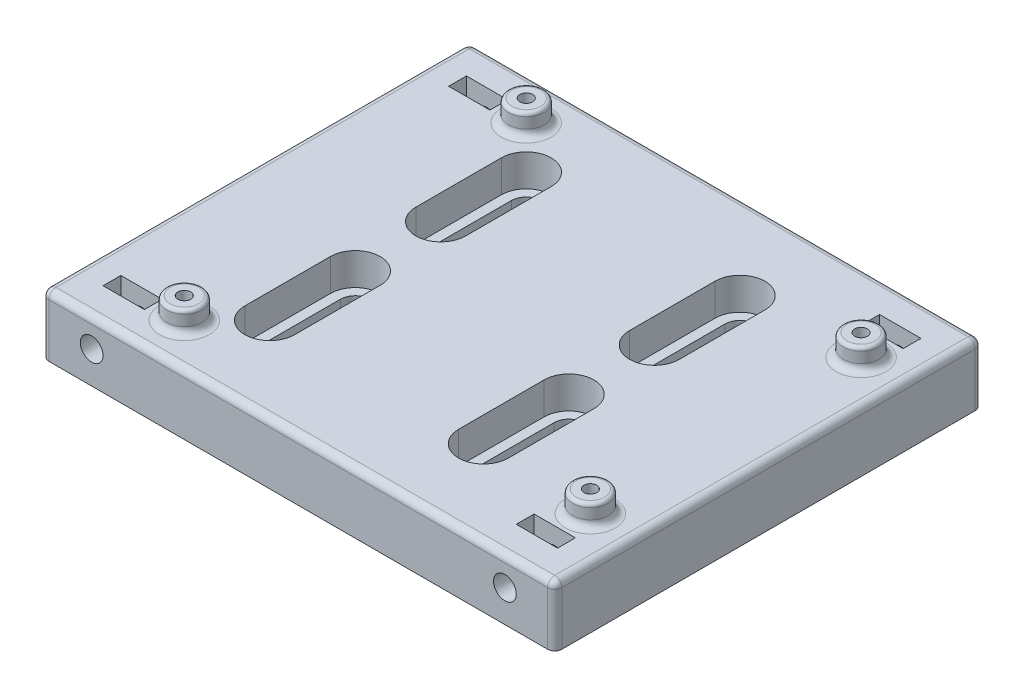
from build123d import *

# Parameters (mm, degrees)
SKETCH1_W           = 70
SKETCH1_H           = 56
BOSS_EXTRUDE1_DEPTH = 4
SKETCH2_W           = 70
SKETCH2_H           = 56
BOSS_EXTRUDE2_DEPTH = 4.5
SKETCH5_W           = 70
SKETCH5_H           = 8.5
BOSS_EXTRUDE3_DEPTH = 2
SKETCH6_W           = 70
SKETCH6_H           = 8.5
BOSS_EXTRUDE4_DEPTH = 2
SKETCH7_R           = 2.5
SKETCH7_R_2         = 0.9
BOSS_EXTRUDE5_DEPTH = 3
FILLET2_R           = 1
FILLET4_R           = 0.5
CUT_EXTRUDE6_START  = -30
SKETCH7_4_R         = 0.9
CUT_EXTRUDE6_DEPTH  = 30
SKETCH8_W           = 60
SKETCH8_H           = 8.5
BOSS_EXTRUDE6_DEPTH = 2
CUT_EXTRUDE2_DEPTH  = 7
SKETCH9_8_R         = 1.6
BOSS_EXTRUDE8_DEPTH = 4.5
SKETCH9_9_R         = 1.6
CUT_EXTRUDE4_DEPTH  = 10
SKETCH11_W          = 74.912856335
SKETCH11_H          = 22.458830191
CUT_EXTRUDE5_DEPTH  = 30
FILLET5_R           = 1


with BuildPart() as part:
    # Sketch1 → Boss-Extrude1 (new body)
    with BuildSketch(Plane(origin=(0, 0, 0), x_dir=(1, 0, 0), z_dir=(0, 1, 0))):
        with Locations((35, -28)):
            Rectangle(SKETCH1_W, SKETCH1_H)
        with BuildLine():
            ThreePointArc((52.1, -22), (50, -24.1), (47.9, -22))
            Line((47.9, -22), (47.9, -10))
            ThreePointArc((47.9, -10), (50, -7.9), (52.1, -10))
            Line((52.1, -10), (52.1, -22))
        make_face(mode=Mode.SUBTRACT)
        with BuildLine():
            ThreePointArc((52.1, -46), (50, -48.1), (47.9, -46))
            Line((47.9, -46), (47.9, -34))
            ThreePointArc((47.9, -34), (50, -31.9), (52.1, -34))
            Line((52.1, -34), (52.1, -46))
        make_face(mode=Mode.SUBTRACT)
        with BuildLine():
            ThreePointArc((17.9, -10), (20, -7.9), (22.1, -10))
            Line((22.1, -10), (22.1, -22))
            ThreePointArc((22.1, -22), (20, -24.1), (17.9, -22))
            Line((17.9, -22), (17.9, -10))
        make_face(mode=Mode.SUBTRACT)
        with BuildLine():
            Line((22.1, -34), (22.1, -46))
            ThreePointArc((22.1, -46), (20, -48.1), (17.9, -46))
            Line((17.9, -46), (17.9, -34))
            ThreePointArc((17.9, -34), (20, -31.9), (22.1, -34))
        make_face(mode=Mode.SUBTRACT)
    extrude(amount=BOSS_EXTRUDE1_DEPTH)

    # Sketch2 → Boss-Extrude2 (add)
    with BuildSketch(Plane(origin=(0, 4, 0), x_dir=(1, 0, 0), z_dir=(0, 1, 0))):
        with Locations((35, -28)):
            Rectangle(SKETCH2_W, SKETCH2_H)
        with BuildLine():
            Line((23.5, -22), (23.5, -10))
            ThreePointArc((23.5, -10), (20, -6.5), (16.5, -10))
            Line((16.5, -10), (16.5, -22))
            ThreePointArc((16.5, -22), (20, -25.5), (23.5, -22))
        make_face(mode=Mode.SUBTRACT)
        with BuildLine():
            Line((46.5, -10), (46.5, -22))
            ThreePointArc((46.5, -22), (50, -25.5), (53.5, -22))
            Line((53.5, -22), (53.5, -10))
            ThreePointArc((53.5, -10), (50, -6.5), (46.5, -10))
        make_face(mode=Mode.SUBTRACT)
        with BuildLine():
            Line((16.5, -34), (16.5, -46))
            ThreePointArc((16.5, -46), (20, -49.5), (23.5, -46))
            Line((23.5, -46), (23.5, -34))
            ThreePointArc((23.5, -34), (20, -30.5), (16.5, -34))
        make_face(mode=Mode.SUBTRACT)
        with BuildLine():
            Line((46.5, -34), (46.5, -46))
            ThreePointArc((46.5, -46), (50, -49.5), (53.5, -46))
            Line((53.5, -46), (53.5, -34))
            ThreePointArc((53.5, -34), (50, -30.5), (46.5, -34))
        make_face(mode=Mode.SUBTRACT)
    extrude(amount=BOSS_EXTRUDE2_DEPTH)

    # Sketch5 → Boss-Extrude3 (add)
    with BuildSketch(Plane.XY.offset(56)):
        with Locations((35, 4.25)):
            Rectangle(SKETCH5_W, SKETCH5_H)
    extrude(amount=BOSS_EXTRUDE3_DEPTH)

    # Sketch6 → Boss-Extrude4 (add)
    with BuildSketch(Plane(origin=(0, 0, 0), x_dir=(-1, 0, 0), z_dir=(0, 0, -1))):
        with Locations((-35, 4.25)):
            Rectangle(SKETCH6_W, SKETCH6_H)
    extrude(amount=BOSS_EXTRUDE4_DEPTH)

    # Sketch7 → Boss-Extrude5 (add)
    # profile 1 of 4: a face of its own
    with BuildSketch(Plane(origin=(0, 8.5, 0), x_dir=(1, 0, 0), z_dir=(0, 1, 0))):
        with Locations((14, -4)):
            Circle(SKETCH7_R)
        with Locations((14, -4)):
            Circle(SKETCH7_R_2, mode=Mode.SUBTRACT)
    # profile 2 of 4: a face of its own
    with BuildSketch(Plane(origin=(0, 8.5, 0), x_dir=(1, 0, 0), z_dir=(0, 1, 0))):
        with Locations((14, -52)):
            Circle(SKETCH7_R)
        with Locations((14, -52)):
            Circle(SKETCH7_R_2, mode=Mode.SUBTRACT)
    # profile 3 of 4: a face of its own
    with BuildSketch(Plane(origin=(0, 8.5, 0), x_dir=(1, 0, 0), z_dir=(0, 1, 0))):
        with Locations((66, -47)):
            Circle(SKETCH7_R)
        with Locations((66, -47)):
            Circle(SKETCH7_R_2, mode=Mode.SUBTRACT)
    # profile 4 of 4: a face of its own
    with BuildSketch(Plane(origin=(0, 8.5, 0), x_dir=(1, 0, 0), z_dir=(0, 1, 0))):
        with Locations((39.372259971, -13.674819386)):
            Circle(SKETCH7_R)
    extrude(amount=BOSS_EXTRUDE5_DEPTH)

    # Fillet2
    fillet2_edges = [part.edges().sort_by_distance(p)[0] for p in [
        (63.5, 8.5, 47),
        (36.872259971, 8.5, 13.674819386),
        (11.5, 8.5, 52),
        (11.5, 8.5, 4),
    ]]
    fillet(fillet2_edges, radius=FILLET2_R)

    # Fillet4
    fillet4_edges = [part.edges().sort_by_distance(p)[0] for p in [
        (63.5, 11.5, 47),
        (36.872259971, 11.5, 13.674819386),
        (11.5, 11.5, 52),
        (11.5, 11.5, 4),
    ]]
    fillet(fillet4_edges, radius=FILLET4_R)

    # Sketch7_4 → Cut-Extrude6 (cut)
    with BuildSketch(Plane(origin=(0, 8.5, 0), x_dir=(1, 0, 0), z_dir=(0, 1, 0)).offset(CUT_EXTRUDE6_START)):
        with Locations((14, -52)):
            Circle(SKETCH7_4_R)
        with Locations((66, -47)):
            Circle(SKETCH7_4_R)
    extrude(amount=CUT_EXTRUDE6_DEPTH, mode=Mode.SUBTRACT)

    # Sketch8 → Boss-Extrude6 (add)
    with BuildSketch(Plane(origin=(70, 0, 0), x_dir=(0, 0, -1), z_dir=(1, 0, 0))):
        with Locations((-28, 4.25)):
            Rectangle(SKETCH8_W, SKETCH8_H)
    extrude(amount=BOSS_EXTRUDE6_DEPTH)

    # Sketch9 → Cut-Extrude2 (cut)
    with BuildSketch(Plane.XY.offset(58)):
        Polygon((4.1, 2.825684219), (7, 1.151368439), (9.9, 2.825684219), (9.9, 8.5), (4.1, 8.5), align=None)
        Polygon((67.9, 8.5), (62.1, 8.5), (62.1, 2.825684219), (65, 1.151368439), (67.9, 2.825684219), align=None)
    extrude(amount=-CUT_EXTRUDE2_DEPTH, mode=Mode.SUBTRACT)

    # Sketch9_8 → Boss-Extrude8 (add)
    # profile 1 of 2: a face of its own
    with BuildSketch(Plane.XY.offset(58)):
        Polygon((4.1, 2.825684219), (7, 1.151368439), (9.9, 2.825684219), (9.9, 8.5), (4.1, 8.5), align=None)
        with Locations((7, 4.5)):
            Circle(SKETCH9_8_R, mode=Mode.SUBTRACT)
    # profile 2 of 2: a face of its own
    with BuildSketch(Plane.XY.offset(58)):
        Polygon((67.9, 8.5), (62.1, 8.5), (62.1, 2.825684219), (65, 1.151368439), (67.9, 2.825684219), align=None)
        with Locations((65, 4.5)):
            Circle(SKETCH9_8_R, mode=Mode.SUBTRACT)
    extrude(amount=-BOSS_EXTRUDE8_DEPTH)

    # Sketch9_9 → Cut-Extrude4 (cut)
    with BuildSketch(Plane.XY.offset(58)):
        with Locations((7, 4.5)):
            Circle(SKETCH9_9_R)
        with Locations((65, 4.5)):
            Circle(SKETCH9_9_R)
    extrude(amount=-CUT_EXTRUDE4_DEPTH, mode=Mode.SUBTRACT)

    # Sketch11 → Cut-Extrude5 (cut)
    with BuildSketch(Plane(origin=(0, 0, -2), x_dir=(-1, 0, 0), z_dir=(0, 0, -1))):
        with Locations((-34.543571832, 11.229415096)):
            Rectangle(SKETCH11_W, SKETCH11_H)
    extrude(amount=-CUT_EXTRUDE5_DEPTH, mode=Mode.SUBTRACT)

    # Mirror2: part across plane


with BuildPart() as part_1:
    add(part.part)
    add(part.part.mirror(Plane.XY.offset(28)))

    # Fillet5
    fillet5_edges = [part_1.edges().sort_by_distance(p)[0] for p in [
        (72, 8.5, 28),
        (36, 8.5, 58),
        (0, 8.5, 28),
        (36, 8.5, -2),
        (0, 4.25, -2),
        (72, 4.25, -2),
        (72, 4.25, 58),
        (0, 4.25, 58),
    ]]
    fillet(fillet5_edges, radius=FILLET5_R)


solid = part_1.part
